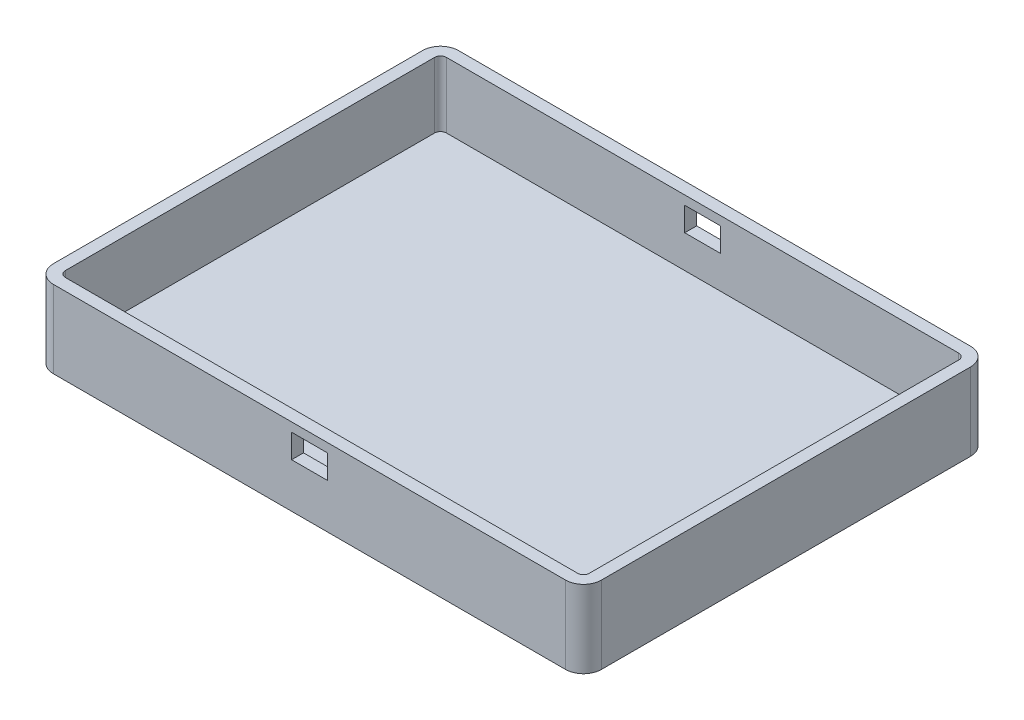
from build123d import *

# Parameters (mm, degrees)
SKETCH1_W               = 92
SKETCH1_H               = 68
BOSS_EXTRUDE1_DEPTH     = 13
FILLET1_R               = 3
SHELL1_T                = -2
SKETCH2_W               = 6
SKETCH2_H               = 4
CUT_EXTRUDE1_DEPTH      = 1
CUT_EXTRUDE1_DEPTH_BACK = 69


with BuildPart() as part:
    # Sketch1 → Boss-Extrude1 (new body)
    with BuildSketch(Plane(origin=(0, 0, 0), x_dir=(1, 0, 0), z_dir=(0, 1, 0))):
        Rectangle(SKETCH1_W, SKETCH1_H)
    extrude(amount=BOSS_EXTRUDE1_DEPTH)

    # Fillet1
    fillet1_edges = [part.edges().sort_by_distance(p)[0] for p in [
        (46, 6.5, 34),
        (-46, 6.5, 34),
        (-46, 6.5, -34),
        (46, 6.5, -34),
    ]]
    fillet(fillet1_edges, radius=FILLET1_R)

    # Shell1
    shell1_openings = [part.faces().sort_by_distance(p)[0] for p in [
        (0, 13, 0),
    ]]
    offset(amount=SHELL1_T, openings=shell1_openings, kind=Kind.INTERSECTION)

    # Sketch2 → Cut-Extrude1 (cut, two sides)
    with BuildSketch(Plane.XY.offset(34)) as cut_extrude1_sk:
        with Locations((0, 9.5)):
            Rectangle(SKETCH2_W, SKETCH2_H)
    extrude(amount=CUT_EXTRUDE1_DEPTH, mode=Mode.SUBTRACT)
    extrude(cut_extrude1_sk.sketch, amount=-CUT_EXTRUDE1_DEPTH_BACK, mode=Mode.SUBTRACT)


solid = part.part
